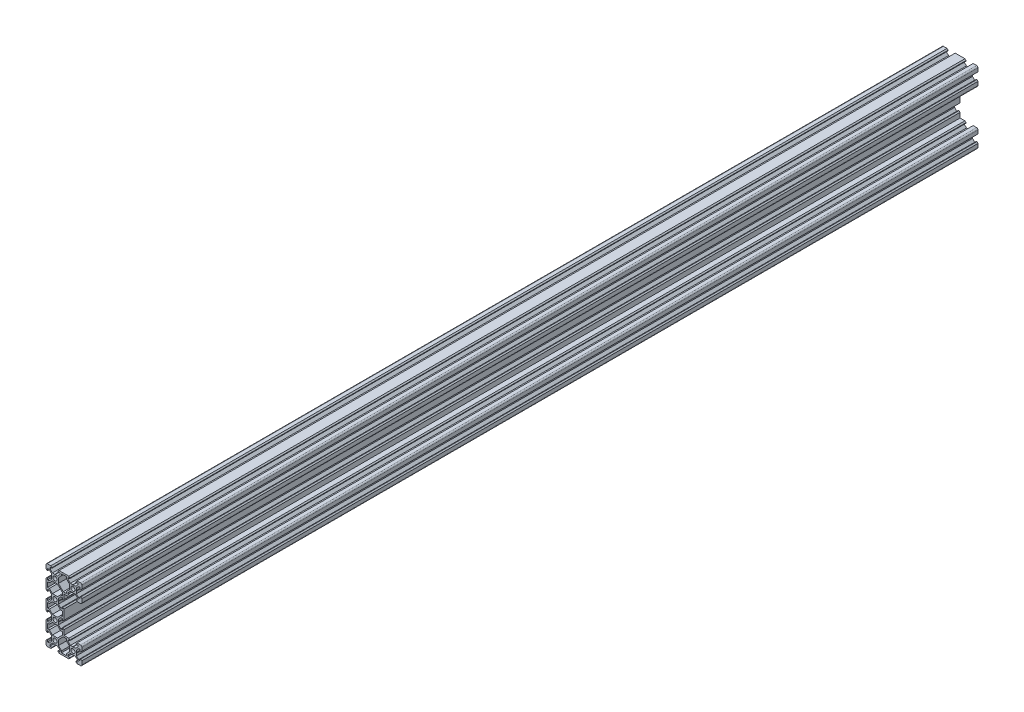
from build123d import *

# Parameters (mm, degrees)
SKETCH1_R           = 2.3
BOSS_EXTRUDE1_DEPTH = 1000


with BuildPart() as part:
    # Sketch1 → Boss-Extrude1 (new body)
    with BuildSketch(Plane.XY):
        with BuildLine():
            Line((-20, -34.58), (-20, -38.5))
            ThreePointArc((-20, -38.5), (-19.560660172, -39.560660172), (-18.5, -40))
            Line((-18.5, -40), (-14.58, -40))
            Line((-14.58, -40), (-13.395, -38.815))
            Line((-13.395, -38.815), (-13.395, -38.2))
            Line((-13.395, -38.2), (-15.5, -38.2))
            Line((-15.5, -38.2), (-15.5, -36.560660172))
            Line((-15.5, -36.560660172), (-12.839339828, -33.9))
            Line((-12.839339828, -33.9), (-10.21, -33.9))
            Line((-10.21, -33.9), (-10, -33.69))
            Line((-10, -33.69), (-9.79, -33.9))
            Line((-9.79, -33.9), (-7.160660172, -33.9))
            Line((-7.160660172, -33.9), (-4.5, -36.560660172))
            Line((-4.5, -36.560660172), (-4.5, -38.2))
            Line((-4.5, -38.2), (-6.605, -38.2))
            Line((-6.605, -38.2), (-6.605, -38.815))
            Line((-6.605, -38.815), (-5.42, -40))
            Line((-5.42, -40), (5.42, -40))
            Line((5.42, -40), (6.605, -38.815))
            Line((6.605, -38.815), (6.605, -38.2))
            Line((6.605, -38.2), (4.5, -38.2))
            Line((4.5, -38.2), (4.5, -36.560660172))
            Line((4.5, -36.560660172), (7.160660172, -33.9))
            Line((7.160660172, -33.9), (9.79, -33.9))
            Line((9.79, -33.9), (10, -33.69))
            Line((10, -33.69), (10.21, -33.9))
            Line((10.21, -33.9), (12.839339828, -33.9))
            Line((12.839339828, -33.9), (15.5, -36.560660172))
            Line((15.5, -36.560660172), (15.5, -38.2))
            Line((15.5, -38.2), (13.395, -38.2))
            Line((13.395, -38.2), (13.395, -38.815))
            Line((13.395, -38.815), (14.58, -40))
            Line((14.58, -40), (18.5, -40))
            ThreePointArc((18.5, -40), (19.560660172, -39.560660172), (20, -38.5))
            Line((20, -38.5), (20, -34.58))
            Line((20, -34.58), (18.815, -33.395))
            Line((18.815, -33.395), (18.2, -33.395))
            Line((18.2, -33.395), (18.2, -35.5))
            Line((18.2, -35.5), (16.560660172, -35.5))
            Line((16.560660172, -35.5), (13.9, -32.839339828))
            Line((13.9, -32.839339828), (13.9, -30.21))
            Line((13.9, -30.21), (13.69, -30))
            Line((13.69, -30), (13.9, -29.79))
            Line((13.9, -29.79), (13.9, -27.160660172))
            Line((13.9, -27.160660172), (16.560660172, -24.5))
            Line((16.560660172, -24.5), (18.2, -24.5))
            Line((18.2, -24.5), (18.2, -26.605))
            Line((18.2, -26.605), (18.815, -26.605))
            Line((18.815, -26.605), (20, -25.42))
            Line((20, -25.42), (20, -21.5))
            ThreePointArc((20, -21.5), (19.560660172, -20.439339828), (18.5, -20))
            Line((18.5, -20), (14.58, -20))
            Line((14.58, -20), (13.395, -21.185))
            Line((13.395, -21.185), (13.395, -21.8))
            Line((13.395, -21.8), (15.5, -21.8))
            Line((15.5, -21.8), (15.5, -23.439339828))
            Line((15.5, -23.439339828), (12.839339828, -26.1))
            Line((12.839339828, -26.1), (10.21, -26.1))
            Line((10.21, -26.1), (10, -26.31))
            Line((10, -26.31), (9.79, -26.1))
            Line((9.79, -26.1), (7.160660172, -26.1))
            Line((7.160660172, -26.1), (4.5, -23.439339828))
            Line((4.5, -23.439339828), (4.5, -21.8))
            Line((4.5, -21.8), (6.605, -21.8))
            Line((6.605, -21.8), (6.605, -21.185))
            Line((6.605, -21.185), (5.42, -20))
            Line((5.42, -20), (0, -20))
            Line((0, -20), (0, -14.58))
            Line((0, -14.58), (-1.185, -13.395))
            Line((-1.185, -13.395), (-1.8, -13.395))
            Line((-1.8, -13.395), (-1.8, -15.5))
            Line((-1.8, -15.5), (-3.439339828, -15.5))
            Line((-3.439339828, -15.5), (-6.1, -12.839339828))
            Line((-6.1, -12.839339828), (-6.1, -10.21))
            Line((-6.1, -10.21), (-6.31, -10))
            Line((-6.31, -10), (-6.1, -9.79))
            Line((-6.1, -9.79), (-6.1, -7.160660172))
            Line((-6.1, -7.160660172), (-3.439339828, -4.5))
            Line((-3.439339828, -4.5), (-1.8, -4.5))
            Line((-1.8, -4.5), (-1.8, -6.605))
            Line((-1.8, -6.605), (-1.185, -6.605))
            Line((-1.185, -6.605), (0, -5.42))
            Line((0, -5.42), (0, 5.42))
            Line((0, 5.42), (-1.185, 6.605))
            Line((-1.185, 6.605), (-1.8, 6.605))
            Line((-1.8, 6.605), (-1.8, 4.5))
            Line((-1.8, 4.5), (-3.439339828, 4.5))
            Line((-3.439339828, 4.5), (-6.1, 7.160660172))
            Line((-6.1, 7.160660172), (-6.1, 9.79))
            Line((-6.1, 9.79), (-6.31, 10))
            Line((-6.31, 10), (-6.1, 10.21))
            Line((-6.1, 10.21), (-6.1, 12.839339828))
            Line((-6.1, 12.839339828), (-3.439339828, 15.5))
            Line((-3.439339828, 15.5), (-1.8, 15.5))
            Line((-1.8, 15.5), (-1.8, 13.395))
            Line((-1.8, 13.395), (-1.185, 13.395))
            Line((-1.185, 13.395), (0, 14.58))
            Line((0, 14.58), (0, 20))
            Line((0, 20), (5.42, 20))
            Line((5.42, 20), (6.605, 21.185))
            Line((6.605, 21.185), (6.605, 21.8))
            Line((6.605, 21.8), (4.5, 21.8))
            Line((4.5, 21.8), (4.5, 23.439339828))
            Line((4.5, 23.439339828), (7.160660172, 26.1))
            Line((7.160660172, 26.1), (9.79, 26.1))
            Line((9.79, 26.1), (10, 26.31))
            Line((10, 26.31), (10.21, 26.1))
            Line((10.21, 26.1), (12.839339828, 26.1))
            Line((12.839339828, 26.1), (15.5, 23.439339828))
            Line((15.5, 23.439339828), (15.5, 21.8))
            Line((15.5, 21.8), (13.395, 21.8))
            Line((13.395, 21.8), (13.395, 21.185))
            Line((13.395, 21.185), (14.58, 20))
            Line((14.58, 20), (18.5, 20))
            ThreePointArc((18.5, 20), (19.560660172, 20.439339828), (20, 21.5))
            Line((20, 21.5), (20, 25.42))
            Line((20, 25.42), (18.815, 26.605))
            Line((18.815, 26.605), (18.2, 26.605))
            Line((18.2, 26.605), (18.2, 24.5))
            Line((18.2, 24.5), (16.560660172, 24.5))
            Line((16.560660172, 24.5), (13.9, 27.160660172))
            Line((13.9, 27.160660172), (13.9, 29.79))
            Line((13.9, 29.79), (13.69, 30))
            Line((13.69, 30), (13.9, 30.21))
            Line((13.9, 30.21), (13.9, 32.839339828))
            Line((13.9, 32.839339828), (16.560660172, 35.5))
            Line((16.560660172, 35.5), (18.2, 35.5))
            Line((18.2, 35.5), (18.2, 33.395))
            Line((18.2, 33.395), (18.815, 33.395))
            Line((18.815, 33.395), (20, 34.58))
            Line((20, 34.58), (20, 38.5))
            ThreePointArc((20, 38.5), (19.560660172, 39.560660172), (18.5, 40))
            Line((18.5, 40), (14.58, 40))
            Line((14.58, 40), (13.395, 38.815))
            Line((13.395, 38.815), (13.395, 38.2))
            Line((13.395, 38.2), (15.5, 38.2))
            Line((15.5, 38.2), (15.5, 36.560660172))
            Line((15.5, 36.560660172), (12.839339828, 33.9))
            Line((12.839339828, 33.9), (10.21, 33.9))
            Line((10.21, 33.9), (10, 33.69))
            Line((10, 33.69), (9.79, 33.9))
            Line((9.79, 33.9), (7.160660172, 33.9))
            Line((7.160660172, 33.9), (4.5, 36.560660172))
            Line((4.5, 36.560660172), (4.5, 38.2))
            Line((4.5, 38.2), (6.605, 38.2))
            Line((6.605, 38.2), (6.605, 38.815))
            Line((6.605, 38.815), (5.42, 40))
            Line((5.42, 40), (-5.42, 40))
            Line((-5.42, 40), (-6.605, 38.815))
            Line((-6.605, 38.815), (-6.605, 38.2))
            Line((-6.605, 38.2), (-4.5, 38.2))
            Line((-4.5, 38.2), (-4.5, 36.560660172))
            Line((-4.5, 36.560660172), (-7.160660172, 33.9))
            Line((-7.160660172, 33.9), (-9.79, 33.9))
            Line((-9.79, 33.9), (-10, 33.69))
            Line((-10, 33.69), (-10.21, 33.9))
            Line((-10.21, 33.9), (-12.839339828, 33.9))
            Line((-12.839339828, 33.9), (-15.5, 36.560660172))
            Line((-15.5, 36.560660172), (-15.5, 38.2))
            Line((-15.5, 38.2), (-13.395, 38.2))
            Line((-13.395, 38.2), (-13.395, 38.815))
            Line((-13.395, 38.815), (-14.58, 40))
            Line((-14.58, 40), (-18.5, 40))
            ThreePointArc((-18.5, 40), (-19.560660172, 39.560660172), (-20, 38.5))
            Line((-20, 38.5), (-20, 34.58))
            Line((-20, 34.58), (-18.815, 33.395))
            Line((-18.815, 33.395), (-18.2, 33.395))
            Line((-18.2, 33.395), (-18.2, 35.5))
            Line((-18.2, 35.5), (-16.560660172, 35.5))
            Line((-16.560660172, 35.5), (-13.9, 32.839339828))
            Line((-13.9, 32.839339828), (-13.9, 30.21))
            Line((-13.9, 30.21), (-13.69, 30))
            Line((-13.69, 30), (-13.9, 29.79))
            Line((-13.9, 29.79), (-13.9, 27.160660172))
            Line((-13.9, 27.160660172), (-16.560660172, 24.5))
            Line((-16.560660172, 24.5), (-18.2, 24.5))
            Line((-18.2, 24.5), (-18.2, 26.605))
            Line((-18.2, 26.605), (-18.815, 26.605))
            Line((-18.815, 26.605), (-20, 25.42))
            Line((-20, 25.42), (-20, 14.58))
            Line((-20, 14.58), (-18.815, 13.395))
            Line((-18.815, 13.395), (-18.2, 13.395))
            Line((-18.2, 13.395), (-18.2, 15.5))
            Line((-18.2, 15.5), (-16.560660172, 15.5))
            Line((-16.560660172, 15.5), (-13.9, 12.839339828))
            Line((-13.9, 12.839339828), (-13.9, 10.21))
            Line((-13.9, 10.21), (-13.69, 10))
            Line((-13.69, 10), (-13.9, 9.79))
            Line((-13.9, 9.79), (-13.9, 7.160660172))
            Line((-13.9, 7.160660172), (-16.560660172, 4.5))
            Line((-16.560660172, 4.5), (-18.2, 4.5))
            Line((-18.2, 4.5), (-18.2, 6.605))
            Line((-18.2, 6.605), (-18.815, 6.605))
            Line((-18.815, 6.605), (-20, 5.42))
            Line((-20, 5.42), (-20, -5.42))
            Line((-20, -5.42), (-18.815, -6.605))
            Line((-18.815, -6.605), (-18.2, -6.605))
            Line((-18.2, -6.605), (-18.2, -4.5))
            Line((-18.2, -4.5), (-16.560660172, -4.5))
            Line((-16.560660172, -4.5), (-13.9, -7.160660172))
            Line((-13.9, -7.160660172), (-13.9, -9.79))
            Line((-13.9, -9.79), (-13.69, -10))
            Line((-13.69, -10), (-13.9, -10.21))
            Line((-13.9, -10.21), (-13.9, -12.839339828))
            Line((-13.9, -12.839339828), (-16.560660172, -15.5))
            Line((-16.560660172, -15.5), (-18.2, -15.5))
            Line((-18.2, -15.5), (-18.2, -13.395))
            Line((-18.2, -13.395), (-18.815, -13.395))
            Line((-18.815, -13.395), (-20, -14.58))
            Line((-20, -14.58), (-20, -25.42))
            Line((-20, -25.42), (-18.815, -26.605))
            Line((-18.815, -26.605), (-18.2, -26.605))
            Line((-18.2, -26.605), (-18.2, -24.5))
            Line((-18.2, -24.5), (-16.560660172, -24.5))
            Line((-16.560660172, -24.5), (-13.9, -27.160660172))
            Line((-13.9, -27.160660172), (-13.9, -29.79))
            Line((-13.9, -29.79), (-13.69, -30))
            Line((-13.69, -30), (-13.9, -30.21))
            Line((-13.9, -30.21), (-13.9, -32.839339828))
            Line((-13.9, -32.839339828), (-16.560660172, -35.5))
            Line((-16.560660172, -35.5), (-18.2, -35.5))
            Line((-18.2, -35.5), (-18.2, -33.395))
            Line((-18.2, -33.395), (-18.815, -33.395))
            Line((-18.815, -33.395), (-20, -34.58))
        make_face()
        with Locations((-10, -30)):
            Circle(SKETCH1_R, mode=Mode.SUBTRACT)
        Polygon((-16.239339828, -22.7), (-18.2, -22.7), (-18.2, -17.3), (-16.239339828, -17.3), (-12.839339828, -13.9), (-7.160660172, -13.9), (-3.760660172, -17.3), (-1.8, -17.3), (-1.8, -20.739339828), (-7.160660172, -26.1), (-12.839339828, -26.1), align=None, mode=Mode.SUBTRACT)
        with Locations((-10, -10)):
            Circle(SKETCH1_R, mode=Mode.SUBTRACT)
        Polygon((2.7, -36.239339828), (2.7, -38.2), (-2.7, -38.2), (-2.7, -36.239339828), (-6.1, -32.839339828), (-6.1, -27.160660172), (-0.739339828, -21.8), (2.7, -21.8), (2.7, -23.760660172), (6.1, -27.160660172), (6.1, -32.839339828), align=None, mode=Mode.SUBTRACT)
        with Locations((10, -30)):
            Circle(SKETCH1_R, mode=Mode.SUBTRACT)
        Polygon((-16.239339828, -2.7), (-18.2, -2.7), (-18.2, 2.7), (-16.239339828, 2.7), (-12.839339828, 6.1), (-7.160660172, 6.1), (-3.760660172, 2.7), (-1.8, 2.7), (-1.8, -2.7), (-3.760660172, -2.7), (-7.160660172, -6.1), (-12.839339828, -6.1), align=None, mode=Mode.SUBTRACT)
        with Locations((-10, 10)):
            Circle(SKETCH1_R, mode=Mode.SUBTRACT)
        Polygon((-16.239339828, 17.3), (-18.2, 17.3), (-18.2, 22.7), (-16.239339828, 22.7), (-12.839339828, 26.1), (-7.160660172, 26.1), (-1.8, 20.739339828), (-1.8, 17.3), (-3.760660172, 17.3), (-7.160660172, 13.9), (-12.839339828, 13.9), align=None, mode=Mode.SUBTRACT)
        with Locations((-10, 30)):
            Circle(SKETCH1_R, mode=Mode.SUBTRACT)
        Polygon((-2.7, 36.239339828), (-2.7, 38.2), (2.7, 38.2), (2.7, 36.239339828), (6.1, 32.839339828), (6.1, 27.160660172), (2.7, 23.760660172), (2.7, 21.8), (-0.739339828, 21.8), (-6.1, 27.160660172), (-6.1, 32.839339828), align=None, mode=Mode.SUBTRACT)
        with Locations((10, 30)):
            Circle(SKETCH1_R, mode=Mode.SUBTRACT)
    extrude(amount=BOSS_EXTRUDE1_DEPTH)


solid = part.part
